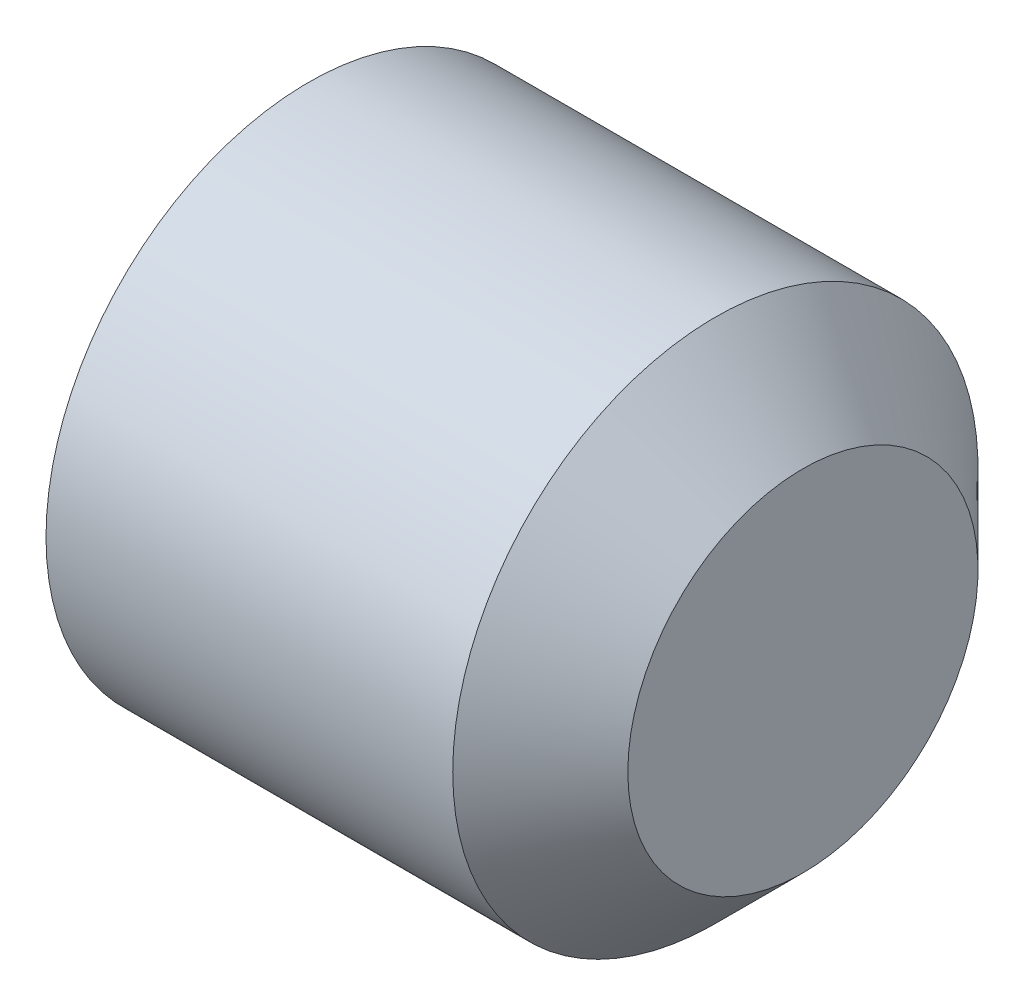
from build123d import *

# Parameters (mm, degrees)
CUT_EXTRUDE1_DEPTH = 1.2


with BuildPart() as part:
    # Sketch1 → Revolve1 (revolve)
    with BuildSketch(Plane.XY):
        Polygon((3, 0), (3, -1), (2.5, -1.5), (0.176957858, -1.5), (0, -1.1935), (0, -0.866025404), (0.5, 0), align=None)
    revolve(axis=Axis((0.5, 0, 0), (1, 0, 0)))

    # Sketch2 → Cut-Extrude1 (cut)
    with BuildSketch(Plane(origin=(0, 0, 0), x_dir=(0, 0, -1), z_dir=(1, 0, 0))):
        Polygon((-0.866025404, 0), (-0.433012702, -0.75), (0.433012702, -0.75), (0.866025404, 0), (0.433012702, 0.75), (-0.433012702, 0.75), align=None)
    extrude(amount=CUT_EXTRUDE1_DEPTH, mode=Mode.SUBTRACT)


solid = part.part
